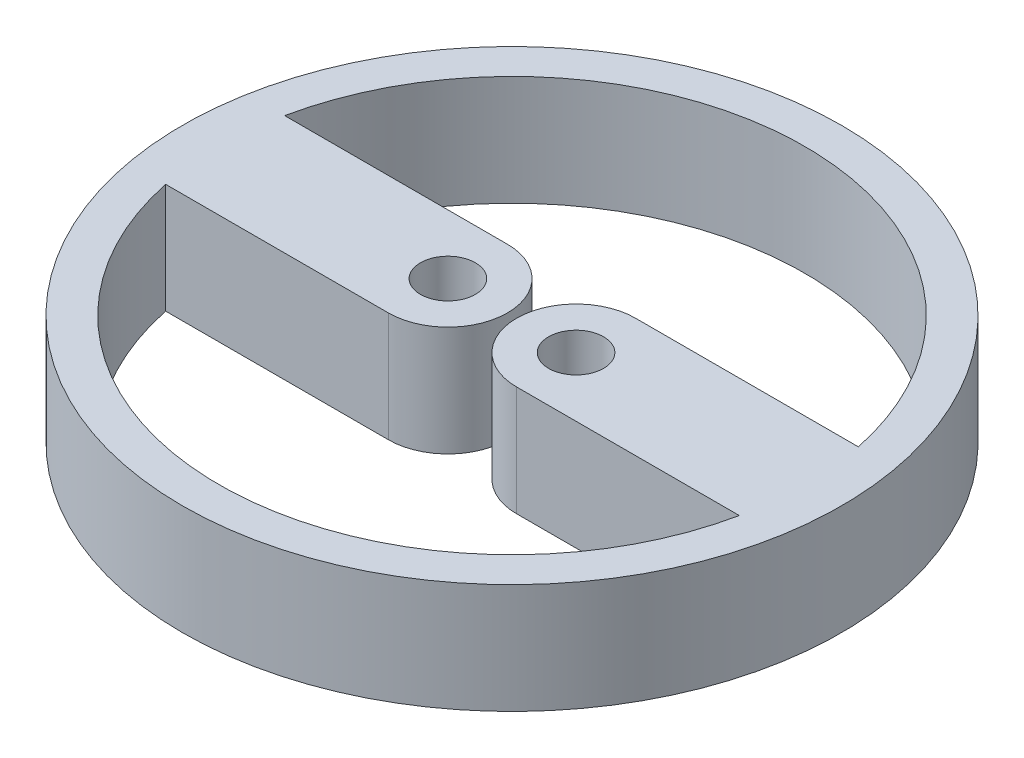
from build123d import *

# Parameters (mm, degrees)
ESQUISSE1_R        = 18
ESQUISSE1_R_2      = 1.5
BOSS_EXTRU_1_DEPTH = 6


with BuildPart() as part:
    # Esquisse1 → Boss.-Extru.1 (new body)
    with BuildSketch(Plane(origin=(0, 0, 0), x_dir=(1, 0, 0), z_dir=(0, 1, 0))):
        Circle(ESQUISSE1_R)
        with Locations((-3.5, 0)):
            Circle(ESQUISSE1_R_2, mode=Mode.SUBTRACT)
        with Locations((3.5, 0)):
            Circle(ESQUISSE1_R_2, mode=Mode.SUBTRACT)
        with BuildLine():
            Line((-3.5, 3.25), (-15.666445034, 3.25))
            ThreePointArc((-15.666445034, 3.25), (0, 16), (15.666445034, 3.25))
            Line((15.666445034, 3.25), (3.5, 3.25))
            ThreePointArc((3.5, 3.25), (0.25, 0), (3.5, -3.25))
            Line((3.5, -3.25), (15.666445034, -3.25))
            ThreePointArc((15.666445034, -3.25), (0, -16), (-15.666445034, -3.25))
            Line((-15.666445034, -3.25), (-3.5, -3.25))
            ThreePointArc((-3.5, -3.25), (-0.25, 0), (-3.5, 3.25))
        make_face(mode=Mode.SUBTRACT)
    extrude(amount=BOSS_EXTRU_1_DEPTH)


solid = part.part
